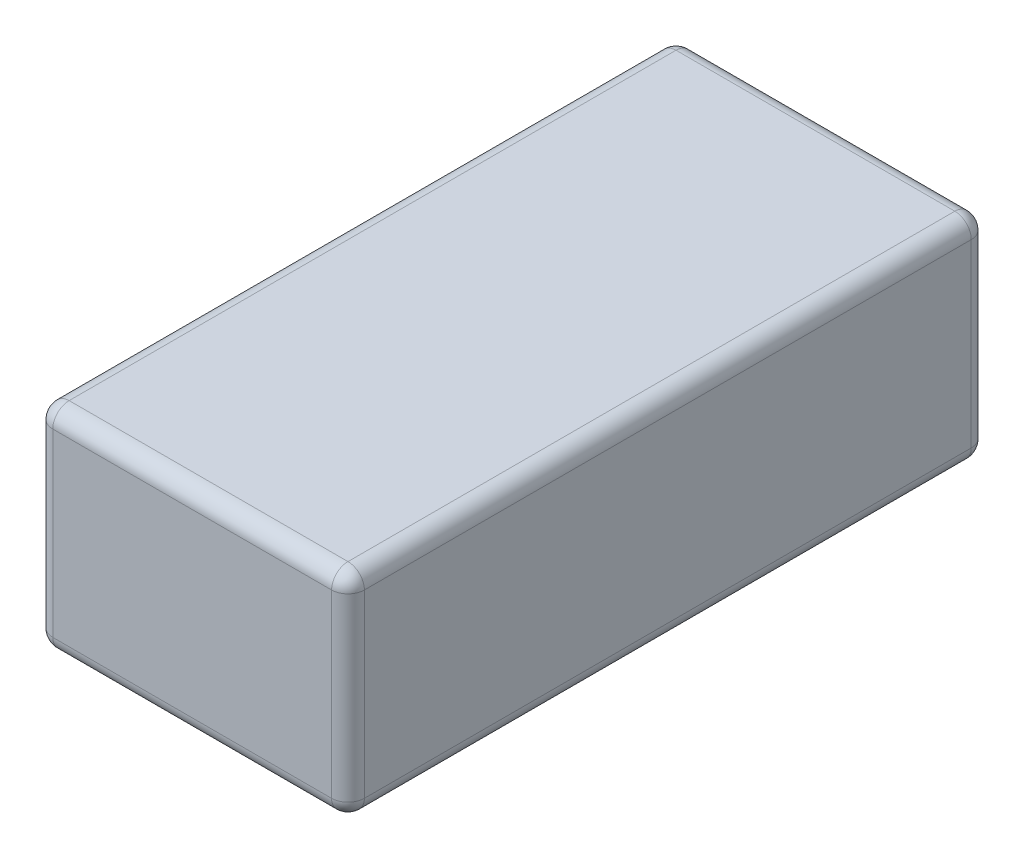
from build123d import *

# Parameters (mm, degrees)
SKETCH1_W           = 95
SKETCH1_H           = 65
BOSS_EXTRUDE1_DEPTH = 195
FILLET1_R           = 5


with BuildPart() as part:
    # Sketch1 → Boss-Extrude1 (new body)
    with BuildSketch(Plane.XY):
        Rectangle(SKETCH1_W, SKETCH1_H)
    extrude(amount=-BOSS_EXTRUDE1_DEPTH)

    # Fillet1
    fillet1_edges = [part.edges().sort_by_distance(p)[0] for p in [
        (47.5, 0, -195),
        (0, 32.5, -195),
        (-47.5, 0, -195),
        (0, 32.5, 0),
        (47.5, 0, 0),
        (0, -32.5, 0),
        (-47.5, 0, 0),
        (-47.5, 32.5, -97.5),
        (47.5, 32.5, -97.5),
        (47.5, -32.5, -97.5),
        (-47.5, -32.5, -97.5),
        (0, -32.5, -195),
    ]]
    fillet(fillet1_edges, radius=FILLET1_R)


solid = part.part
